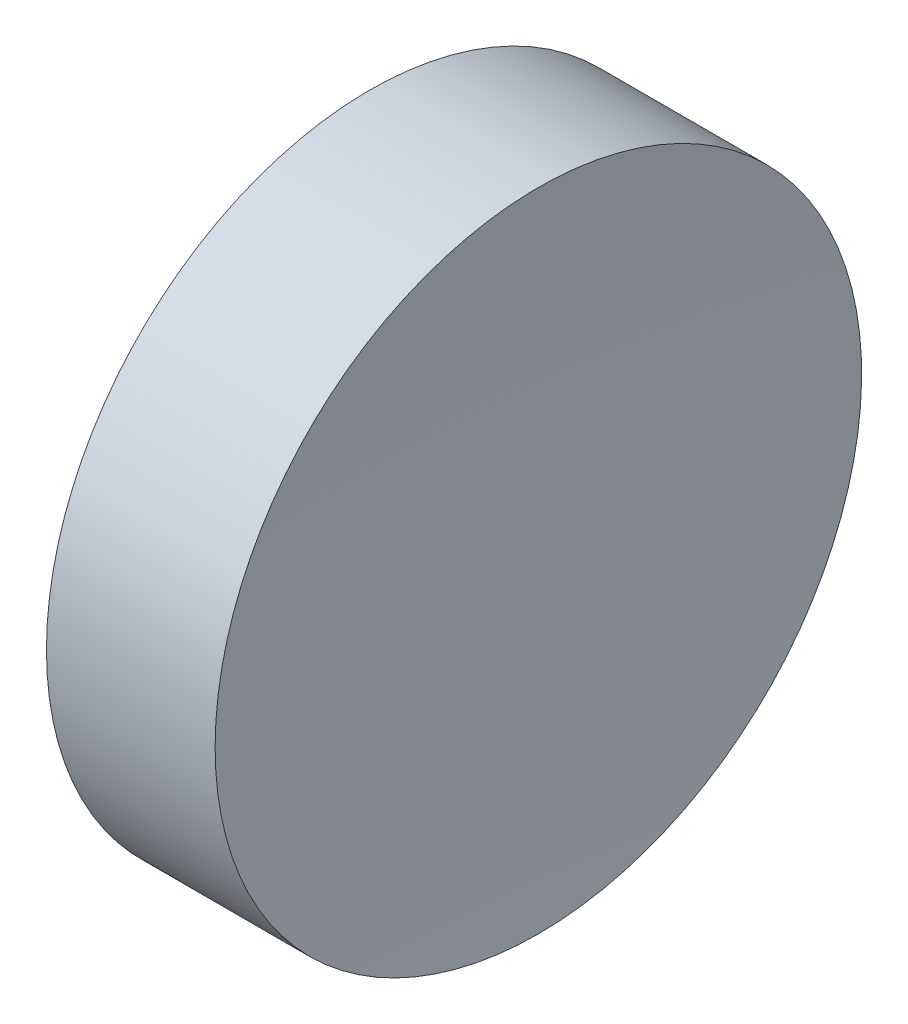
from build123d import *


with BuildPart() as part:
    # 草图1 → 旋转1 (revolve)
    with BuildSketch(Plane.XY, mode=Mode.PRIVATE) as revolve_1_sk:
        with BuildLine():
            Line((115.092655535, 69.378021123), (115.092655535, 81.878021123))
            Line((115.092655535, 81.878021123), (121.614396471, 81.878021123))
            ThreePointArc((121.614396471, 81.878021123), (121.223147698, 75.633463022), (121.09265576, 69.378021123))
            Line((121.09265576, 69.378021123), (115.092655535, 69.378021123))
        make_face()
    revolve(revolve_1_sk.sketch.rotate(Axis((108.985143002, 69.378021123, 0), (1, 0, 0)), 180), axis=Axis((108.985143002, 69.378021123, 0), (1, 0, 0)))  # turned: the seam where the file's is


solid = part.part
